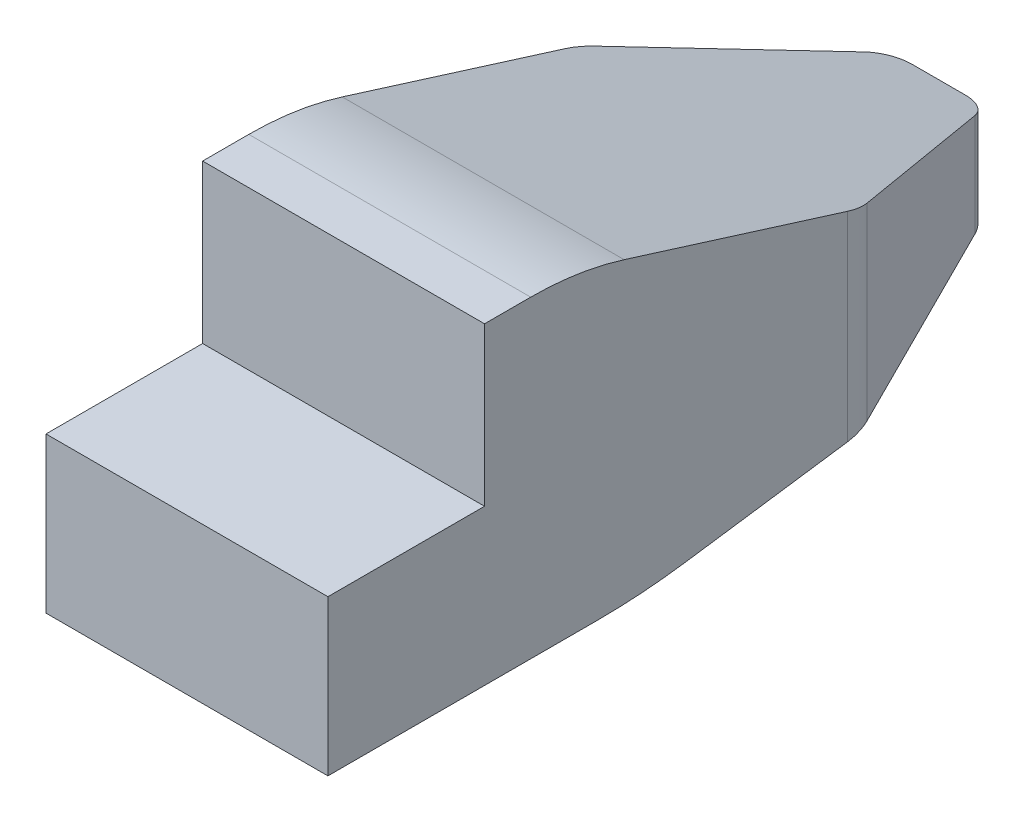
from build123d import *

# Parameters (mm, degrees)
SKETCH_1_W          = 9
SKETCH_1_H          = 24
EXTRUDE_1_DEPTH     = 10
SKETCH_2_W          = 9
SKETCH_2_H          = 5
CUT_EXTRUDE_1_DEPTH = 5.04505
CUT_EXTRUDE_2_DEPTH = 10
CUT_EXTRUDE_4_DEPTH = 11
FILLET_1_R          = 20
FILLET_2_R          = 1
FILLET_3_R          = 2
FILLET_4_R          = 10


with BuildPart() as part:
    # ｽｹｯﾁ1 → ﾎﾞｽ - 押し出し1 (new body)
    with BuildSketch(Plane(origin=(0, 0, 0), x_dir=(1, 0, 0), z_dir=(0, 1, 0))):
        with Locations((4.5, 12)):
            Rectangle(SKETCH_1_W, SKETCH_1_H)
    extrude(amount=EXTRUDE_1_DEPTH)

    # ｽｹｯﾁ2 → ｶｯﾄ - 押し出し1 (cut)
    with BuildSketch(Plane(origin=(0, 10, 0), x_dir=(1, 0, 0), z_dir=(0, 1, 0))):
        with Locations((4.5, 2.5)):
            Rectangle(SKETCH_2_W, SKETCH_2_H)
    extrude(amount=-CUT_EXTRUDE_1_DEPTH, mode=Mode.SUBTRACT)

    # ｽｹｯﾁ3 → ｶｯﾄ - 押し出し2 (cut, through all)
    with BuildSketch(Plane(origin=(9, 0, 0), x_dir=(0, 0, -1), z_dir=(1, 0, 0))):
        Polygon((8, 10), (24, 5), (24, 10), align=None)
        Polygon((10, 0), (24, 0), (24, 2), align=None)
    extrude(amount=-CUT_EXTRUDE_2_DEPTH, mode=Mode.SUBTRACT)

    # ｽｹｯﾁ6 → ｶｯﾄ - 押し出し4 (cut, through all)
    with BuildSketch(Plane.XZ):
        Polygon((9, -24), (9, -17), (6, -24), align=None)
        Polygon((3, -24), (0, -17), (0, -24), align=None)
    extrude(amount=-CUT_EXTRUDE_4_DEPTH, mode=Mode.SUBTRACT)

    # ﾌｨﾚｯﾄ1
    fillet_1_edges = [part.edges().sort_by_distance(p)[0] for p in [
        (4.5, 0, -10),
    ]]
    fillet(fillet_1_edges, radius=FILLET_1_R)

    # ﾌｨﾚｯﾄ2
    fillet_2_edges = [part.edges().sort_by_distance(p)[0] for p in [
        (6, 3.5, -24),
        (3, 3.5, -24),
    ]]
    fillet(fillet_2_edges, radius=FILLET_2_R)

    # ﾌｨﾚｯﾄ3
    fillet_3_edges = [part.edges().sort_by_distance(p)[0] for p in [
        (9, 4.09375, -17),
        (0, 4.09375, -17),
    ]]
    fillet(fillet_3_edges, radius=FILLET_3_R)

    # ﾌｨﾚｯﾄ4
    fillet_4_edges = [part.edges().sort_by_distance(p)[0] for p in [
        (4.5, 10, -8),
    ]]
    fillet(fillet_4_edges, radius=FILLET_4_R)


solid = part.part
